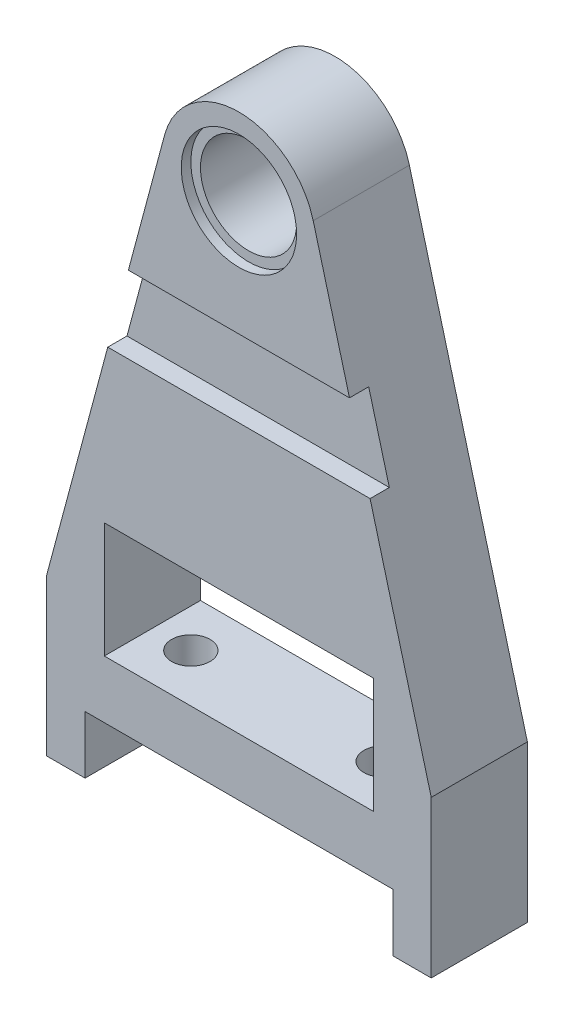
from build123d import *

# Parameters (mm, degrees)
SKETCH1_R           = 25
SKETCH1_W           = 140
SKETCH1_H           = 60
BOSS_EXTRUDE1_DEPTH = 25
SKETCH4_R           = 30
CUT_EXTRUDE1_DEPTH  = 5
CUT_EXTRUDE2_DEPTH  = 10
CUT_EXTRUDE3_REACH  = 312
SKETCH6_R           = 10


with BuildPart() as part:
    # Sketch1 → Boss-Extrude1 (new body, symmetric)
    with BuildSketch(Plane.XY):
        with BuildLine():
            Line((100, 81.343051449), (38.637033052, 310.352761804))
            ThreePointArc((38.637033052, 310.352761804), (0, 340), (-38.637033052, 310.352761804))
            Line((-38.637033052, 310.352761804), (-100, 81.343051449))
            Line((-100, 81.343051449), (-100, 0))
            Line((-100, 0), (-80, 0))
            Line((-80, 0), (-80, 30))
            Line((-80, 30), (80, 30))
            Line((80, 30), (80, 0))
            Line((80, 0), (100, 0))
            Line((100, 0), (100, 81.343051449))
        make_face()
        with Locations((0, 300)):
            Circle(SKETCH1_R, mode=Mode.SUBTRACT)
        with Locations((0, 90)):
            Rectangle(SKETCH1_W, SKETCH1_H, mode=Mode.SUBTRACT)
    extrude(amount=BOSS_EXTRUDE1_DEPTH, both=True)

    # Sketch4 → Cut-Extrude1 (cut)
    with BuildSketch(Plane.XY.offset(25)):
        with Locations((0, 300)):
            Circle(SKETCH4_R)
    cut_extrude1 = extrude(amount=-CUT_EXTRUDE1_DEPTH, mode=Mode.SUBTRACT)

    # Mirror1: Cut-Extrude1 across plane
    add(cut_extrude1.mirror(Plane.XY), mode=Mode.SUBTRACT)

    # Sketch5 → Cut-Extrude2 (cut)
    with BuildSketch(Plane.XY.offset(25)):
        Polygon((-57.487998762, 240), (57.487998762, 240), (68.20596646, 200), (-68.20596646, 200), align=None)
    extrude(amount=-CUT_EXTRUDE2_DEPTH, mode=Mode.SUBTRACT)

    # Sketch6 → Cut-Extrude3 (cut, up to next)
    with BuildSketch(Plane.XZ.offset(-30), mode=Mode.PRIVATE) as cut_extrude3_sk1:
        with Locations((-50, 0)):
            Circle(SKETCH6_R)
    cut_extrude3_tool1 = extrude(cut_extrude3_sk1.sketch, amount=-CUT_EXTRUDE3_REACH, mode=Mode.PRIVATE) & part.part
    add(cut_extrude3_tool1.solids().sort_by_distance((-50, 30, 0))[0], mode=Mode.SUBTRACT)
    # Sketch6 → Cut-Extrude3 (cut, up to next)
    with BuildSketch(Plane.XZ.offset(-30), mode=Mode.PRIVATE) as cut_extrude3_sk2:
        with Locations((50, 0)):
            Circle(SKETCH6_R)
    cut_extrude3_tool2 = extrude(cut_extrude3_sk2.sketch, amount=-CUT_EXTRUDE3_REACH, mode=Mode.PRIVATE) & part.part
    add(cut_extrude3_tool2.solids().sort_by_distance((50, 30, 0))[0], mode=Mode.SUBTRACT)


solid = part.part
